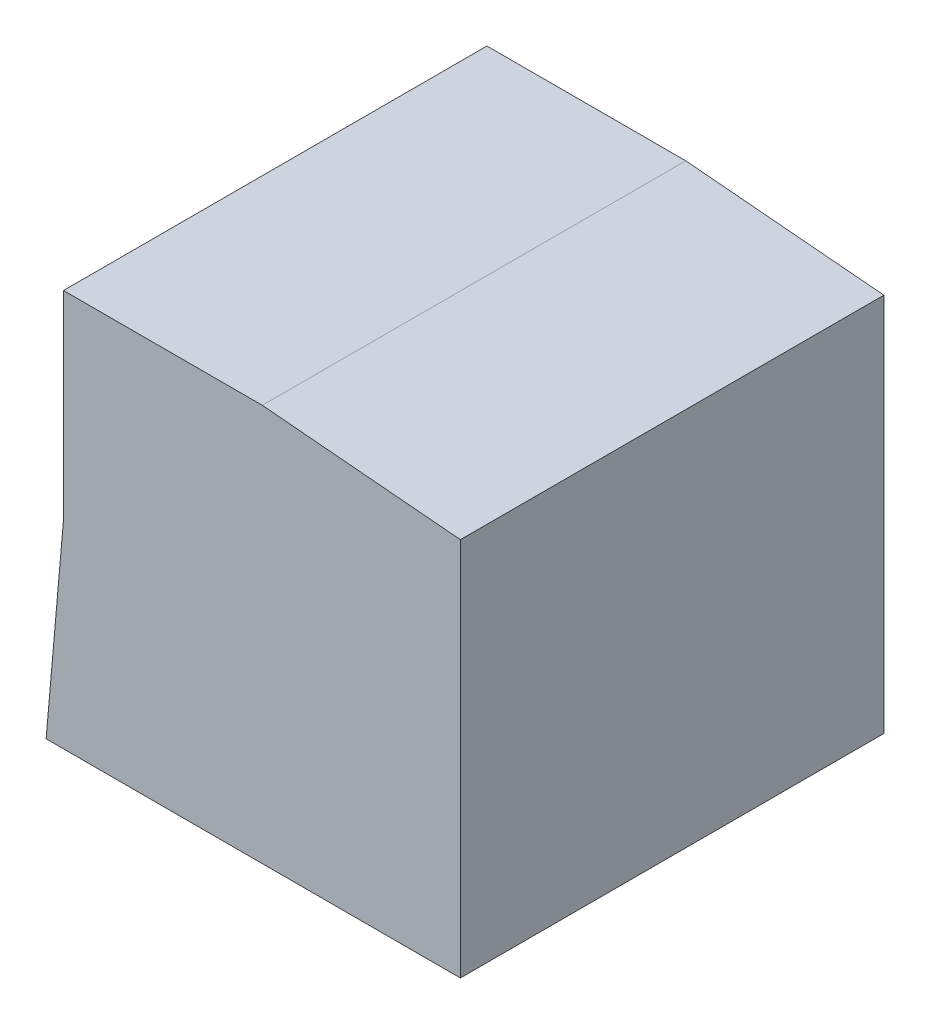
from build123d import *

# Parameters (mm, degrees)
AUFSATZ_LINEAR_AUSTRAGEN1_DEPTH = 40


with BuildPart() as part:
    # Skizze1 → Aufsatz-Linear austragen1 (new body)
    with BuildSketch(Plane.XY):
        Polygon((0, -18.781845947), (-1.636945734, -37.492221299), (37.492221299, -37.492221299), (37.492221299, -1.636945734), (18.781845947, 0), (0, 0), align=None)
    extrude(amount=AUFSATZ_LINEAR_AUSTRAGEN1_DEPTH)


solid = part.part
